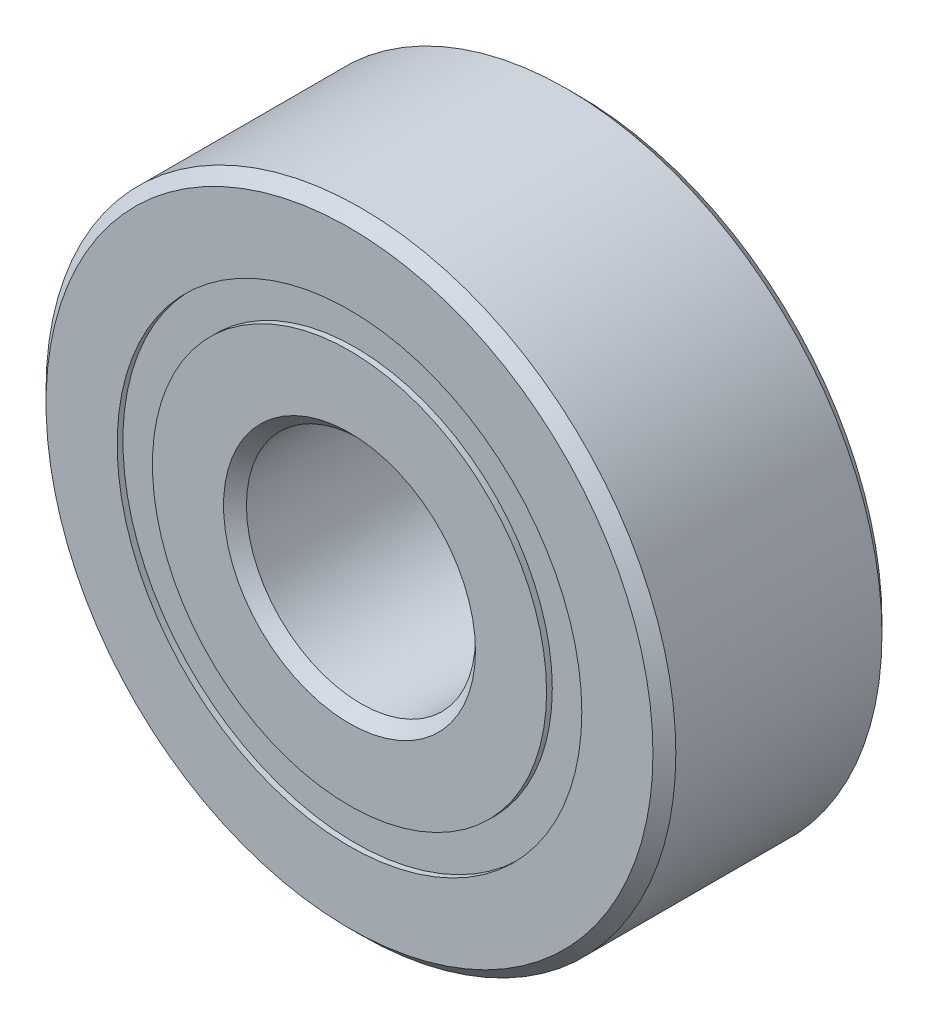
from build123d import *

# Parameters (mm, degrees)
CIRPATTERN1_COUNT = 12
SKETCH5_W         = 0.959362975
SKETCH5_H         = 0.615384616


with BuildPart() as part:
    # Sketch1 → Revolve1 (revolve)
    with BuildSketch(Plane(origin=(0, 0, 0), x_dir=(0, 0, -1), z_dir=(1, 0, 0))):
        with BuildLine():
            Line((1.8, 5.5), (-1.8, 5.5))
            Line((-1.8, 5.5), (-2, 5.3))
            Line((-2, 5.3), (-2, 4.057692308))
            Line((-2, 4.057692308), (-0.888888889, 4.057692308))
            ThreePointArc((-0.888888889, 4.057692308), (0, 4.690637025), (0.888888889, 4.057692308))
            Line((0.888888889, 4.057692308), (2, 4.057692308))
            Line((2, 4.057692308), (2, 5.3))
            Line((2, 5.3), (1.8, 5.5))
        make_face()
    revolve(axis=Axis((0, 0, 2), (0, 0, -1)))


with BuildPart() as body_2:
    # Sketch3 → Revolve3 (revolve)
    with BuildSketch(Plane(origin=(0, 0, 0), x_dir=(0, 0, -1), z_dir=(1, 0, 0))):
        with BuildLine():
            Line((-2, 3.442307692), (-0.888888889, 3.442307692))
            ThreePointArc((-0.888888889, 3.442307692), (0, 2.809362975), (0.888888889, 3.442307692))
            Line((0.888888889, 3.442307692), (2, 3.442307692))
            Line((2, 3.442307692), (2, 2.2))
            Line((2, 2.2), (1.8, 2))
            Line((1.8, 2), (-1.8, 2))
            Line((-1.8, 2), (-2, 2.2))
            Line((-2, 2.2), (-2, 3.442307692))
        make_face()
    revolve(axis=Axis((0, 0, 2), (0, 0, -1)))


with BuildPart() as body_3:
    # Sketch4 → Revolve4 (revolve)
    with BuildSketch(Plane(origin=(0, 0, 0), x_dir=(0, 0, -1), z_dir=(1, 0, 0))):
        with BuildLine():
            Line((-0.940637025, 3.75), (0.940637025, 3.75))
            ThreePointArc((0.940637025, 3.75), (0, 4.690637025), (-0.940637025, 3.75))
        make_face()
    revolve(axis=Axis((0, 3.75, 0.940637025), (0, 0, -1)))


with BuildPart() as cirpattern1_1:
    # CirPattern1: pattern copy
    add(body_3.part.rotate(Axis((0, 0, -2), (0, 0, 1)), 1 * 360 / CIRPATTERN1_COUNT))


with BuildPart() as cirpattern1_2:
    # CirPattern1: pattern copy
    add(body_3.part.rotate(Axis((0, 0, -2), (0, 0, 1)), 2 * 360 / CIRPATTERN1_COUNT))


with BuildPart() as cirpattern1_3:
    # CirPattern1: pattern copy
    add(body_3.part.rotate(Axis((0, 0, -2), (0, 0, 1)), 3 * 360 / CIRPATTERN1_COUNT))


with BuildPart() as cirpattern1_4:
    # CirPattern1: pattern copy
    add(body_3.part.rotate(Axis((0, 0, -2), (0, 0, 1)), 4 * 360 / CIRPATTERN1_COUNT))


with BuildPart() as cirpattern1_5:
    # CirPattern1: pattern copy
    add(body_3.part.rotate(Axis((0, 0, -2), (0, 0, 1)), 5 * 360 / CIRPATTERN1_COUNT))


with BuildPart() as cirpattern1_6:
    # CirPattern1: pattern copy
    add(body_3.part.rotate(Axis((0, 0, -2), (0, 0, 1)), 6 * 360 / CIRPATTERN1_COUNT))


with BuildPart() as cirpattern1_7:
    # CirPattern1: pattern copy
    add(body_3.part.rotate(Axis((0, 0, -2), (0, 0, 1)), 7 * 360 / CIRPATTERN1_COUNT))


with BuildPart() as cirpattern1_8:
    # CirPattern1: pattern copy
    add(body_3.part.rotate(Axis((0, 0, -2), (0, 0, 1)), 8 * 360 / CIRPATTERN1_COUNT))


with BuildPart() as cirpattern1_9:
    # CirPattern1: pattern copy
    add(body_3.part.rotate(Axis((0, 0, -2), (0, 0, 1)), 9 * 360 / CIRPATTERN1_COUNT))


with BuildPart() as cirpattern1_10:
    # CirPattern1: pattern copy
    add(body_3.part.rotate(Axis((0, 0, -2), (0, 0, 1)), 10 * 360 / CIRPATTERN1_COUNT))


with BuildPart() as cirpattern1_11:
    # CirPattern1: pattern copy
    add(body_3.part.rotate(Axis((0, 0, -2), (0, 0, 1)), 11 * 360 / CIRPATTERN1_COUNT))


with BuildPart() as body_15:
    # Sketch5 → Revolve5 (revolve)
    with BuildSketch(Plane(origin=(0, 0, 0), x_dir=(0, 0, -1), z_dir=(1, 0, 0))):
        with Locations((-1.420318513, 3.75)):
            Rectangle(SKETCH5_W, SKETCH5_H)
        with Locations((1.420318513, 3.75)):
            Rectangle(SKETCH5_W, SKETCH5_H)
    revolve(axis=Axis((0, 0, 2), (0, 0, -1)))


solid = Compound([part.part, body_2.part, body_3.part, cirpattern1_1.part, cirpattern1_2.part, cirpattern1_3.part, cirpattern1_4.part, cirpattern1_5.part, cirpattern1_6.part, cirpattern1_7.part, cirpattern1_8.part, cirpattern1_9.part, cirpattern1_10.part, cirpattern1_11.part, body_15.part])
